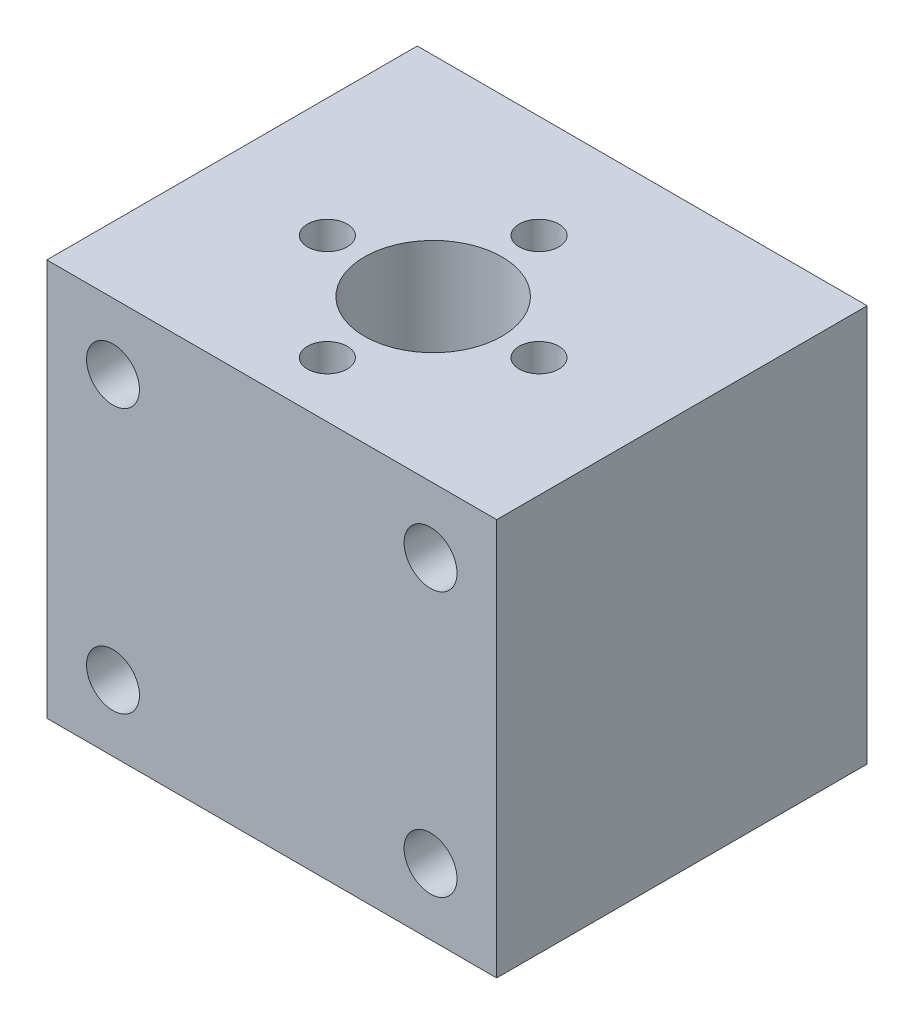
from build123d import *

# Parameters (mm, degrees)
SKETCH_1_W          = 34
SKETCH_1_H          = 30
EXTRUDE_1_DEPTH     = 28
SKETCH_2_R          = 2
CUT_EXTRUDE_1_DEPTH = 7
SKETCH_3_R          = 5.2
CUT_EXTRUDE_3_DEPTH = 31
SKETCH_5_R          = 1.5
CUT_EXTRUDE_4_DEPTH = 7


with BuildPart() as part:
    # 草图1 → 凸台-拉伸1 (new body)
    with BuildSketch(Plane.XY):
        with Locations((0.688013078, -5.139852888)):
            Rectangle(SKETCH_1_W, SKETCH_1_H)
    extrude(amount=-EXTRUDE_1_DEPTH)

    # 草图2 → 切除-拉伸1 (cut)
    with BuildSketch(Plane.XY):
        with Locations((-11.311986922, 4.86014711)):
            Circle(SKETCH_2_R)
        with Locations((12.688013078, 4.86014711)):
            Circle(SKETCH_2_R)
        with Locations((12.688013078, -15.13985289)):
            Circle(SKETCH_2_R)
        with Locations((-11.311986922, -15.13985289)):
            Circle(SKETCH_2_R)
    extrude(amount=-CUT_EXTRUDE_1_DEPTH, mode=Mode.SUBTRACT)

    # 草图3 → 切除-拉伸3 (cut, through all)
    with BuildSketch(Plane(origin=(0, 9.860147112, 0), x_dir=(1, 0, 0), z_dir=(0, 1, 0))):
        with Locations((0.688013078, 12.2)):
            Circle(SKETCH_3_R)
    extrude(amount=-CUT_EXTRUDE_3_DEPTH, mode=Mode.SUBTRACT)

    # 草图5 → 切除-拉伸4 (cut)
    with BuildSketch(Plane(origin=(0, 9.860147112, 0), x_dir=(1, 0, 0), z_dir=(0, 1, 0))):
        with Locations((0.688013078, 4.2)):
            Circle(SKETCH_5_R)
        with Locations((8.688013078, 12.2)):
            Circle(SKETCH_5_R)
        with Locations((0.688013078, 20.2)):
            Circle(SKETCH_5_R)
        with Locations((-7.311986922, 12.2)):
            Circle(SKETCH_5_R)
    extrude(amount=-CUT_EXTRUDE_4_DEPTH, mode=Mode.SUBTRACT)


solid = part.part
